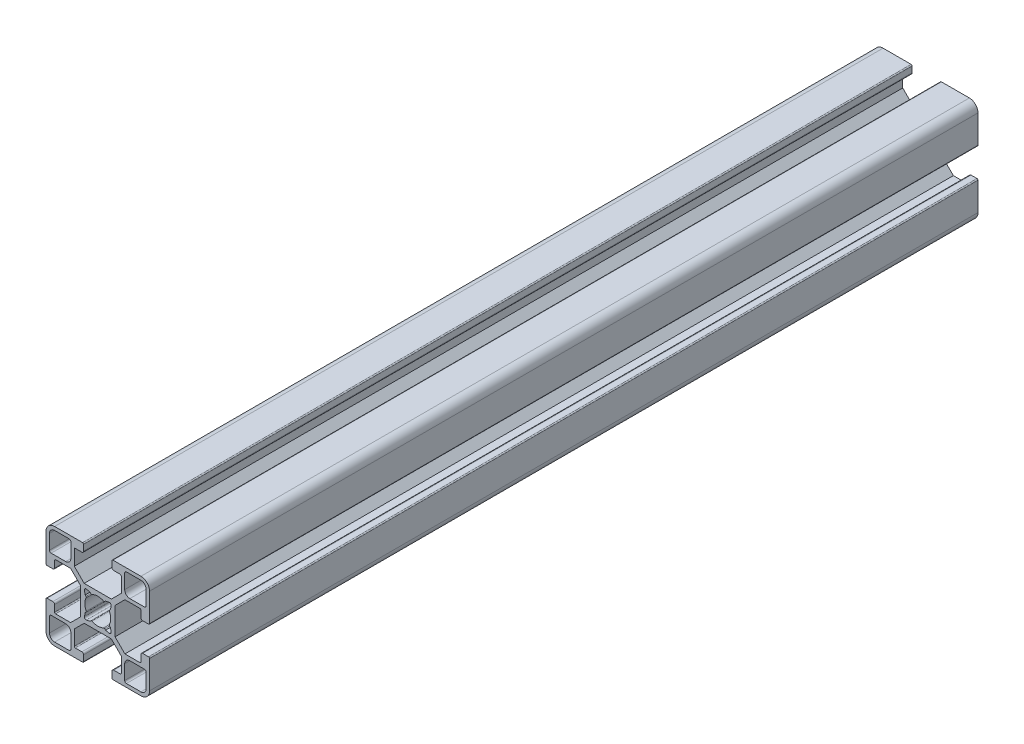
from build123d import *

# Parameters (mm, degrees)
BOSS_EXTRUDE1_DEPTH = 120


with BuildPart() as part:
    # Sketch1 → Boss-Extrude1 (new body, symmetric)
    with BuildSketch(Plane.XY):
        with BuildLine():
            Line((21.799994, 7.139358412), (18.939339529, 9.999998412))
            Line((18.939339529, 9.999998412), (11.060658529, 9.999998412))
            Line((11.060658529, 9.999998412), (8.200003529, 7.139342412))
            Line((8.200003529, 7.139342412), (8.200003529, 2.800001412))
            ThreePointArc((8.200003529, 2.800001412), (8.287868495, 2.58786762), (8.500000529, 2.499998412))
            Line((8.500000529, 2.499998412), (10.400000529, 2.499998412))
            ThreePointArc((10.400000529, 2.499998412), (10.75355392, 2.353551802), (10.900000529, 1.999998412))
            Line((10.900000529, 1.999998412), (10.900000529, 0.299995529))
            ThreePointArc((10.900000529, 0.299995529), (10.812133796, 0.08786744), (10.600006, 0))
            Line((10.600006, 0), (2.5, 0))
            ThreePointArc((2.5, 0), (0.732233047, 0.732233047), (0, 2.5))
            Line((0, 2.5), (0, 10.600006))
            ThreePointArc((0, 10.600006), (0.087869562, 10.812137388), (0.300003, 10.900002))
            Line((0.300003, 10.900002), (2, 10.900002))
            ThreePointArc((2, 10.900002), (2.353553391, 10.753555391), (2.5, 10.400002))
            Line((2.5, 10.400002), (2.5, 8.500002))
            ThreePointArc((2.5, 8.500002), (2.587869099, 8.287870075), (2.80000269, 8.200005))
            Line((2.80000269, 8.200005), (7.139344, 8.200005))
            Line((7.139344, 8.200005), (10, 11.06066))
            Line((10, 11.06066), (10, 18.939341))
            Line((10, 18.939341), (7.139344, 21.799985148))
            Line((7.139344, 21.799985148), (2.800003, 21.799985148))
            ThreePointArc((2.800003, 21.799985148), (2.587872691, 21.712123666), (2.5, 21.499998))
            Line((2.5, 21.499998), (2.5, 19.599988398))
            ThreePointArc((2.5, 19.599988398), (2.353553317, 19.246434831), (1.99999975, 19.099988148))
            Line((1.99999975, 19.099988148), (0.299996735, 19.099988148))
            ThreePointArc((0.299996735, 19.099988148), (0.0878677, 19.187854622), (0, 19.399983148))
            Line((0, 19.399983148), (0, 27.499989148))
            ThreePointArc((0, 27.499989148), (0.732232787, 29.267756841), (2.500000265, 29.999990148))
            Line((2.500000265, 29.999990148), (10.6000062, 29.999990148))
            ThreePointArc((10.6000062, 29.999990148), (10.812133482, 29.912123021), (10.900000529, 29.699995706))
            Line((10.900000529, 29.699995706), (10.900000529, 27.999998706))
            ThreePointArc((10.900000529, 27.999998706), (10.753556384, 27.64644081), (10.400000529, 27.499991736))
            Line((10.400000529, 27.499991736), (8.499998529, 27.499991736))
            ThreePointArc((8.499998529, 27.499991736), (8.287867897, 27.41212193), (8.200003529, 27.199989046))
            Line((8.200003529, 27.199989046), (8.200003529, 22.860646736))
            Line((8.200003529, 22.860646736), (11.060659, 19.999991736))
            Line((11.060659, 19.999991736), (18.93934, 19.999991736))
            Line((18.93934, 19.999991736), (21.799994, 22.860646736))
            Line((21.799994, 22.860646736), (21.799994, 27.199988736))
            ThreePointArc((21.799994, 27.199988736), (21.712128868, 27.412122694), (21.499996529, 27.499991736))
            Line((21.499996529, 27.499991736), (19.599998, 27.499991736))
            ThreePointArc((19.599998, 27.499991736), (19.246444609, 27.646438346), (19.099998, 27.999991736))
            Line((19.099998, 27.999991736), (19.099998, 29.700007823))
            ThreePointArc((19.099998, 29.700007823), (19.187864526, 29.912137383), (19.3999935, 30.000005323))
            Line((19.3999935, 30.000005323), (27.4999995, 30.000005323))
            ThreePointArc((27.4999995, 30.000005323), (29.267773609, 29.267772326), (30.000009773, 27.499999529))
            Line((30.000009773, 27.499999529), (30.000009773, 19.399993594))
            ThreePointArc((30.000009773, 19.399993594), (29.912139919, 19.187852468), (29.6999965, 19.099988148))
            Line((29.6999965, 19.099988148), (27.9999995, 19.099988148))
            ThreePointArc((27.9999995, 19.099988148), (27.64645275, 19.246438389), (27.500009772, 19.599988147))
            Line((27.500009772, 19.599988147), (27.500009772, 21.499990147))
            ThreePointArc((27.500009772, 21.499990147), (27.412139967, 21.712120779), (27.200007083, 21.799985148))
            Line((27.200007083, 21.799985148), (22.860664773, 21.799985148))
            Line((22.860664773, 21.799985148), (20.000009773, 18.939341))
            Line((20.000009773, 18.939341), (20.000009773, 11.06066))
            Line((20.000009773, 11.06066), (22.8606545, 8.200005))
            Line((22.8606545, 8.200005), (27.1999965, 8.200005))
            ThreePointArc((27.1999965, 8.200005), (27.412129602, 8.287869277), (27.499999499, 8.500000052))
            Line((27.499999499, 8.500000052), (27.499999499, 10.400002001))
            ThreePointArc((27.499999499, 10.400002001), (27.646446109, 10.753555391), (27.9999995, 10.900002))
            Line((27.9999995, 10.900002), (29.7000025, 10.900002))
            ThreePointArc((29.7000025, 10.900002), (29.912138814, 10.812138492), (30.000009773, 10.600005265))
            Line((30.000009773, 10.600005265), (30.000009773, 2.499999265))
            ThreePointArc((30.000009773, 2.499999265), (29.267773942, 0.732224081), (27.500000177, -1.5175e-05))
            Line((27.500000177, -1.5175e-05), (19.399994245, -1.5175e-05))
            ThreePointArc((19.399994245, -1.5175e-05), (19.187855627, 0.08786137), (19.099998, 0.300007824))
            Line((19.099998, 0.300007824), (19.099998, 2.000004824))
            ThreePointArc((19.099998, 2.000004824), (19.246446356, 2.353553549), (19.599996529, 2.499998412))
            Line((19.599996529, 2.499998412), (21.499998529, 2.499998412))
            ThreePointArc((21.499998529, 2.499998412), (21.712135123, 2.587873708), (21.799994, 2.800017102))
            Line((21.799994, 2.800017102), (21.799994, 7.139358412))
        make_face()
        with BuildLine():
            Line((18.878868942, 11.714100014), (18.657285002, 12.75690673))
            Line((18.657285002, 12.75690673), (18.419345869, 12.994846743))
            ThreePointArc((18.419345869, 12.994846743), (18.335473622, 13.158180995), (18.362480424, 13.339793948))
            ThreePointArc((18.362480424, 13.339793948), (18.750006156, 14.99998656), (18.362487962, 16.660180933))
            ThreePointArc((18.362487962, 16.660180933), (18.335481889, 16.841794157), (18.419354758, 17.005128271))
            Line((18.419354758, 17.005128271), (18.657294593, 17.243067582))
            Line((18.657294593, 17.243067582), (18.878893628, 18.28587109))
            ThreePointArc((18.878893628, 18.28587109), (18.743367928, 18.743355263), (18.285883756, 18.878880962))
            Line((18.285883756, 18.878880962), (17.243080247, 18.657281928))
            Line((17.243080247, 18.657281928), (17.005140412, 18.419342617))
            ThreePointArc((17.005140412, 18.419342617), (16.84180664, 18.335470316), (16.660194009, 18.362476539))
            ThreePointArc((16.660194009, 18.362476539), (15.00000526, 18.749996344), (13.339816433, 18.362476869))
            ThreePointArc((13.339816433, 18.362476869), (13.158203164, 18.335470716), (12.994869031, 18.419343671))
            Line((12.994869031, 18.419343671), (12.756929898, 18.657283684))
            Line((12.756929898, 18.657283684), (11.714126233, 18.878881984))
            ThreePointArc((11.714126233, 18.878881984), (11.256641967, 18.743355772), (11.121116891, 18.28587117))
            Line((11.121116891, 18.28587117), (11.342717777, 17.243068055))
            Line((11.342717777, 17.243068055), (11.580656587, 17.00512772))
            ThreePointArc((11.580656587, 17.00512772), (11.664528478, 16.841794182), (11.637522309, 16.660181943))
            ThreePointArc((11.637522309, 16.660181943), (11.250003617, 14.999998075), (11.637519652, 13.339813587))
            ThreePointArc((11.637519652, 13.339813587), (11.664525497, 13.15820068), (11.580652734, 12.994866901))
            Line((11.580652734, 12.994866901), (11.342712898, 12.75692759))
            Line((11.342712898, 12.75692759), (11.12111194, 11.71412449))
            ThreePointArc((11.12111194, 11.71412449), (11.256636795, 11.256640068), (11.714120718, 11.121113524))
            Line((11.714120718, 11.121113524), (12.756924635, 11.342710635))
            Line((12.756924635, 11.342710635), (12.99486447, 11.580649946))
            ThreePointArc((12.99486447, 11.580649946), (13.158198441, 11.66452228), (13.339811235, 11.637515845))
            ThreePointArc((13.339811235, 11.637515845), (14.999988879, 11.249993804), (16.660169832, 11.637501672))
            ThreePointArc((16.660169832, 11.637501672), (16.841782614, 11.664506717), (17.005115943, 11.580633605))
            Line((17.005115943, 11.580633605), (17.243054753, 11.34269327))
            Line((17.243054753, 11.34269327), (18.285858839, 11.12109695))
            ThreePointArc((18.285858839, 11.12109695), (18.743339639, 11.256620822), (18.878868942, 11.714100014))
        make_face(mode=Mode.SUBTRACT)
        with BuildLine():
            Line((23.299995, 1), (27.5, 1))
            ThreePointArc((27.5, 1), (28.56065669, 1.439341852), (28.999994597, 2.500000176))
            Line((28.999994597, 2.500000176), (28.999994597, 6.700005176))
            ThreePointArc((28.999994597, 6.700005176), (28.853547926, 7.053558453), (28.499994597, 7.200005))
            Line((28.499994597, 7.200005), (24.299995, 7.200005))
            ThreePointArc((24.299995, 7.200005), (23.239334828, 6.760665172), (22.799995, 5.700005))
            Line((22.799995, 5.700005), (22.799995, 1.5))
            ThreePointArc((22.799995, 1.5), (22.946441609, 1.146446609), (23.299995, 1))
        make_face(mode=Mode.SUBTRACT)
        with BuildLine():
            Line((2.5, 1), (6.700005, 1))
            ThreePointArc((6.700005, 1), (7.05355839, 1.146446609), (7.200005, 1.5))
            Line((7.200005, 1.5), (7.200005, 5.700005))
            ThreePointArc((7.200005, 5.700005), (6.760665172, 6.760665172), (5.700005, 7.200005))
            Line((5.700005, 7.200005), (1.5, 7.200005))
            ThreePointArc((1.5, 7.200005), (1.146446609, 7.053558391), (1, 6.700005))
            Line((1, 6.700005), (1, 2.5))
            ThreePointArc((1, 2.5), (1.439339828, 1.439339828), (2.5, 1))
        make_face(mode=Mode.SUBTRACT)
        with BuildLine():
            Line((1.5, 22.799985148), (5.700005, 22.799985148))
            ThreePointArc((5.700005, 22.799985148), (6.760665172, 23.239324976), (7.200005, 24.299985148))
            Line((7.200005, 24.299985148), (7.200005, 28.499990148))
            ThreePointArc((7.200005, 28.499990148), (7.053558391, 28.853543539), (6.700005, 28.999990148))
            Line((6.700005, 28.999990148), (2.5, 28.999990148))
            ThreePointArc((2.5, 28.999990148), (1.439339828, 28.56065032), (1, 27.499990148))
            Line((1, 27.499990148), (1, 23.299985148))
            ThreePointArc((1, 23.299985148), (1.146446609, 22.946431757), (1.5, 22.799985148))
        make_face(mode=Mode.SUBTRACT)
        with BuildLine():
            Line((24.299995, 22.799985148), (28.499994597, 22.799985148))
            ThreePointArc((28.499994597, 22.799985148), (28.853551502, 22.946435272), (28.999994597, 23.299995088))
            Line((28.999994597, 23.299995088), (28.999994597, 27.500000088))
            ThreePointArc((28.999994597, 27.500000088), (28.560656076, 28.560654835), (27.5, 28.999990148))
            Line((27.5, 28.999990148), (23.299995, 28.999990148))
            ThreePointArc((23.299995, 28.999990148), (22.94644161, 28.853543539), (22.799995, 28.499990148))
            Line((22.799995, 28.499990148), (22.799995, 24.299985148))
            ThreePointArc((22.799995, 24.299985148), (23.239334828, 23.239324976), (24.299995, 22.799985148))
        make_face(mode=Mode.SUBTRACT)
    extrude(amount=BOSS_EXTRUDE1_DEPTH, both=True)


solid = part.part
